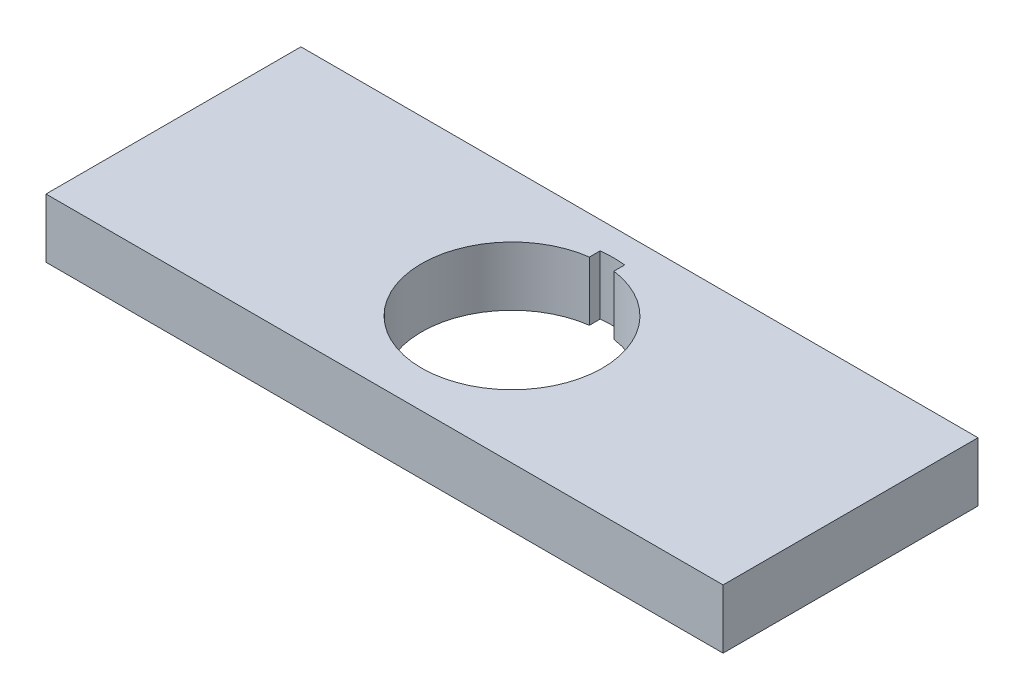
from build123d import *

# Parameters (mm, degrees)
SKETCH1_W           = 66.4
SKETCH1_H           = 5.8
BOSS_EXTRUDE1_DEPTH = 25
SKETCH2_R           = 8.875
CUT_EXTRUDE1_DEPTH  = 6.8
CUT_EXTRUDE2_DEPTH  = 6.8


with BuildPart() as part:
    # Sketch1 → Boss-Extrude1 (new body)
    with BuildSketch(Plane.XY):
        with Locations((0, 59.6)):
            Rectangle(SKETCH1_W, SKETCH1_H)
    extrude(amount=BOSS_EXTRUDE1_DEPTH)

    # Sketch2 → Cut-Extrude1 (cut, through all)
    with BuildSketch(Plane(origin=(0, 62.5, 0), x_dir=(1, 0, 0), z_dir=(0, 1, 0))):
        with Locations((0, -12.500000019)):
            Circle(SKETCH2_R)
    extrude(amount=-CUT_EXTRUDE1_DEPTH, mode=Mode.SUBTRACT)

    # Sketch3 → Cut-Extrude2 (cut, through all)
    with BuildSketch(Plane.XZ.offset(-56.7)):
        with BuildLine():
            Line((-1.2, 3.706501), (1.2, 3.706501))
            Line((1.2, 3.706501), (1.2, 2.657885155))
            ThreePointArc((1.2, 2.657885155), (0, 2.585000019), (-1.2, 2.657885155))
            Line((-1.2, 2.657885155), (-1.2, 3.706501))
        make_face()
    extrude(amount=-CUT_EXTRUDE2_DEPTH, mode=Mode.SUBTRACT)


solid = part.part
